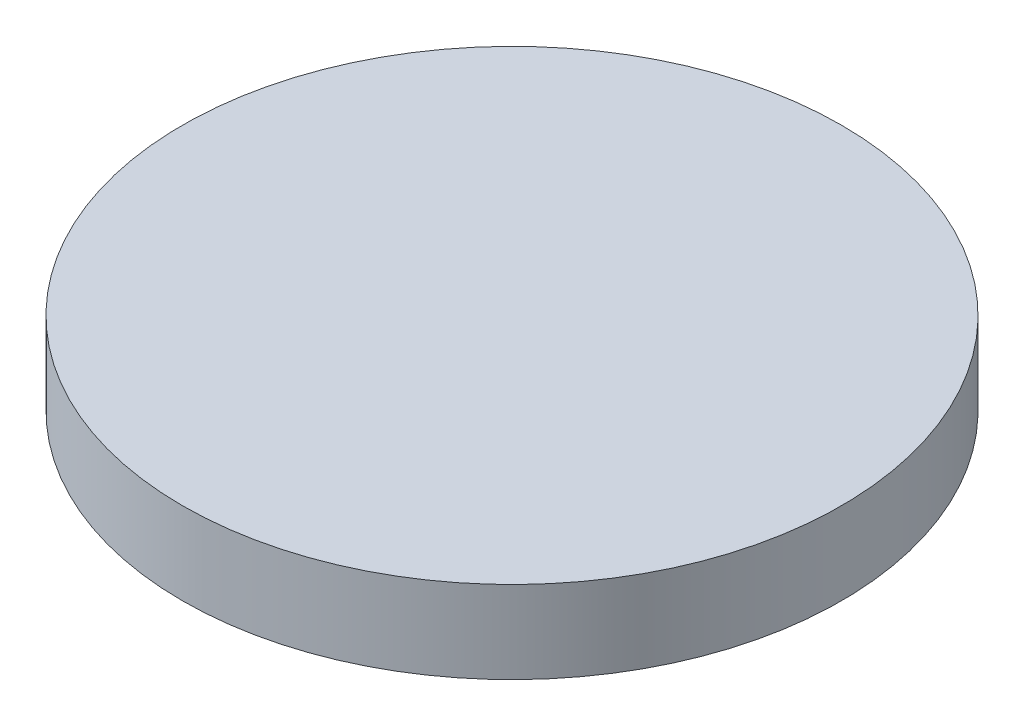
from build123d import *

# Parameters (mm, degrees)
SKETCH_1_R      = 152.4
EXTRUDE_1_DEPTH = 38.1


with BuildPart() as part:
    # 草图1 → 凸台-拉伸1 (new body)
    with BuildSketch(Plane(origin=(0, 0, 0), x_dir=(1, 0, 0), z_dir=(0, 1, 0))):
        with Locations(Location((0, 0, 0), (0, 0, 270))):  # turned: the seam where the file's is
            Circle(SKETCH_1_R)
    extrude(amount=EXTRUDE_1_DEPTH)


solid = part.part
